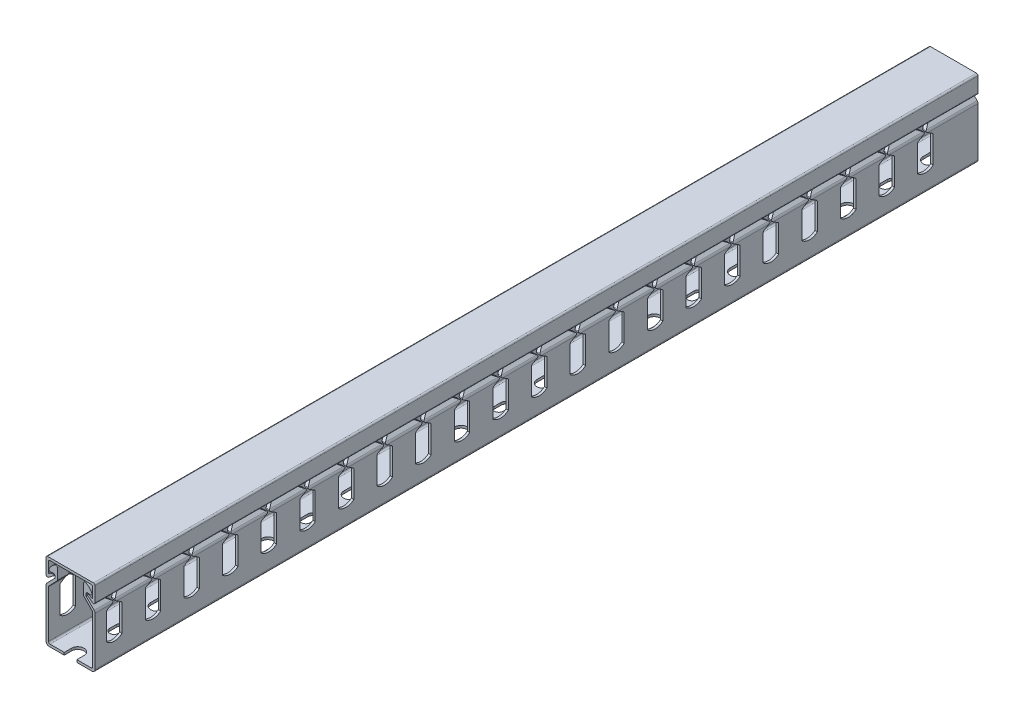
from build123d import *

# Parameters (mm, degrees)
BOSS_EXTRUDE1_DEPTH        = 228.6
BOSS_EXTRUDE1_DEPTH_BACK   = 228.6
BOSS_EXTRUDE1_2_DEPTH      = 228.6
BOSS_EXTRUDE1_2_DEPTH_BACK = 228.6
FILLET1_R                  = 0.254
FILLET2_R                  = 0.79375
FILLET3_R                  = 1.5875
FILLET4_R                  = 0.79375
CUT_EXTRUDE2_DEPTH         = 13.7
LPATTERN2_COUNT            = 22
LPATTERN2_PITCH            = 20
CUT_EXTRUDE3_DEPTH         = 1.27
CUT_EXTRUDE4_DEPTH         = 1.27
LPATTERN3_COUNT            = 10
LPATTERN3_PITCH            = 50


with BuildPart() as part:
    # Sketch5 → Boss-Extrude1 (new body, two sides)
    with BuildSketch(Plane.XY) as boss_extrude1_sk:
        with BuildLine():
            Line((-6.80847, 17.42825), (-6.80847, 11.601073654))
            Line((-6.80847, 11.601073654), (-11.43, 6.8817226))
            Line((-11.43, 6.8817226), (-11.43, -18.73))
            Line((-11.43, -18.73), (11.43, -18.73))
            Line((11.43, -18.73), (11.43, 6.8817226))
            Line((11.43, 6.8817226), (6.80847, 11.601073654))
            Line((6.80847, 11.601073654), (6.80847, 17.42825))
            ThreePointArc((6.80847, 17.42825), (7.19761808, 18.11113824), (7.983490721, 18.124433668))
            ThreePointArc((7.983490721, 18.124433668), (9.75568161, 16.763244384), (11.032082377, 14.929042133))
            ThreePointArc((11.032082377, 14.929042133), (10.954803473, 14.106067876), (10.187743463, 13.798045804))
            Line((10.187743463, 13.798045804), (8.07847, 14.151017128))
            Line((8.07847, 14.151017128), (8.07847, 12.119351053))
            Line((8.07847, 12.119351053), (12.7, 7.4))
            Line((12.7, 7.4), (12.7, -20))
            Line((12.7, -20), (-12.7, -20))
            Line((-12.7, -20), (-12.7, 7.4))
            Line((-12.7, 7.4), (-8.07847, 12.119351053))
            Line((-8.07847, 12.119351053), (-8.07847, 14.151017128))
            Line((-8.07847, 14.151017128), (-10.187743463, 13.798045804))
            ThreePointArc((-10.187743463, 13.798045804), (-10.954803473, 14.106067876), (-11.032082377, 14.929042133))
            ThreePointArc((-11.032082377, 14.929042133), (-9.75568161, 16.763244384), (-7.983490721, 18.124433668))
            ThreePointArc((-7.983490721, 18.124433668), (-7.19761808, 18.11113824), (-6.80847, 17.42825))
        make_face()
    extrude(amount=BOSS_EXTRUDE1_DEPTH)
    extrude(boss_extrude1_sk.sketch, amount=-BOSS_EXTRUDE1_DEPTH_BACK)

    # Fillet3
    fillet3_edges = [part.edges().sort_by_distance(p)[0] for p in [
        (12.7, 7.4, 0),
        (12.7, -20, 0),
        (-12.7, -20, 0),
        (-12.7, 7.4, 0),
    ]]
    fillet(fillet3_edges, radius=FILLET3_R)

    # Fillet4
    fillet4_edges = [part.edges().sort_by_distance(p)[0] for p in [
        (-6.80847, 11.601073654, 0),
        (-11.43, 6.8817226, 0),
        (-11.43, -18.73, 0),
        (11.43, -18.73, 0),
        (11.43, 6.8817226, 0),
        (6.80847, 11.601073654, 0),
        (8.07847, 14.151017128, 0),
        (-8.07847, 14.151017128, 0),
    ]]
    fillet(fillet4_edges, radius=FILLET4_R)

    # Sketch6 → Cut-Extrude2 (cut, symmetric)
    with BuildSketch(Plane(origin=(0, 0, 0), x_dir=(0, 0, -1), z_dir=(1, 0, 0))):
        with BuildLine():
            Line((-222.6, 20), (-222.6, 10.281402782))
            ThreePointArc((-222.6, 10.281402782), (-222.501317282, 9.898100634), (-222.229806522, 9.610106323))
            Line((-222.229806522, 9.610106323), (-219.258970247, 7.735648229))
            ThreePointArc((-219.258970247, 7.735648229), (-219.073873508, 7.4), (-219.258970247, 7.064351771))
            Line((-219.258970247, 7.064351771), (-222.229806522, 5.189893677))
            ThreePointArc((-222.229806522, 5.189893677), (-222.501317282, 4.901899366), (-222.6, 4.518597218))
            Line((-222.6, 4.518597218), (-222.6, -9.1796))
            ThreePointArc((-222.6, -9.1796), (-218.6, -10.707464045), (-214.6, -9.1796))
            Line((-214.6, -9.1796), (-214.6, 4.518597218))
            ThreePointArc((-214.6, 4.518597218), (-214.698682718, 4.901899366), (-214.970193478, 5.189893677))
            Line((-214.970193478, 5.189893677), (-217.941029753, 7.064351771))
            ThreePointArc((-217.941029753, 7.064351771), (-218.126126492, 7.4), (-217.941029753, 7.735648229))
            Line((-217.941029753, 7.735648229), (-214.970193478, 9.610106323))
            ThreePointArc((-214.970193478, 9.610106323), (-214.698682718, 9.898100634), (-214.6, 10.281402782))
            Line((-214.6, 10.281402782), (-214.6, 20))
            Line((-214.6, 20), (-222.6, 20))
        make_face()
    cut_extrude2 = extrude(amount=CUT_EXTRUDE2_DEPTH, both=True, mode=Mode.SUBTRACT)

    # LPattern2: Cut-Extrude2 ×22
    with Locations(*[(0, 0, -i * LPATTERN2_PITCH) for i in range(1, LPATTERN2_COUNT)]):
        add(cut_extrude2, mode=Mode.SUBTRACT)

    # Sketch7 → Cut-Extrude3 (cut)
    with BuildSketch(Plane.XZ.offset(20)):
        with BuildLine():
            Line((-3.25, 232.35), (-3.25, 224.85))
            ThreePointArc((-3.25, 224.85), (0, 221.6), (3.25, 224.85))
            Line((3.25, 224.85), (3.25, 232.35))
            ThreePointArc((3.25, 232.35), (0, 235.6), (-3.25, 232.35))
        make_face()
        with BuildLine():
            Line((-2.25, 206.1), (-2.25, 202.6))
            ThreePointArc((-2.25, 202.6), (0, 200.35), (2.25, 202.6))
            Line((2.25, 202.6), (2.25, 206.1))
            ThreePointArc((2.25, 206.1), (0, 208.35), (-2.25, 206.1))
        make_face()
    extrude(amount=-CUT_EXTRUDE3_DEPTH, mode=Mode.SUBTRACT)

    # Sketch8 → Cut-Extrude4 (cut)
    with BuildSketch(Plane.XZ.offset(20)):
        with BuildLine():
            Line((-2.25, 153.35), (-2.25, 156.85))
            ThreePointArc((-2.25, 156.85), (0, 159.1), (2.25, 156.85))
            Line((2.25, 156.85), (2.25, 153.35))
            ThreePointArc((2.25, 153.35), (0, 151.1), (-2.25, 153.35))
        make_face()
        with BuildLine():
            Line((3.25, 183.85), (3.25, 176.35))
            ThreePointArc((3.25, 176.35), (0, 173.1), (-3.25, 176.35))
            Line((-3.25, 176.35), (-3.25, 183.85))
            ThreePointArc((-3.25, 183.85), (0, 187.1), (3.25, 183.85))
        make_face()
    cut_extrude4 = extrude(amount=-CUT_EXTRUDE4_DEPTH, mode=Mode.SUBTRACT)

    # LPattern3: Cut-Extrude4 ×10
    with Locations(*[(0, 0, -i * LPATTERN3_PITCH) for i in range(1, LPATTERN3_COUNT)]):
        add(cut_extrude4, mode=Mode.SUBTRACT)


with BuildPart() as body_2:
    # Sketch5 → Boss-Extrude1 2 (new body, two sides)
    with BuildSketch(Plane.XY) as boss_extrude1_2_sk:
        with BuildLine():
            Line((-12.7, 20), (-12.7, 11.49227))
            ThreePointArc((-12.7, 11.49227), (-12.263515638, 10.783467964), (-11.434109413, 10.854208617))
            Line((-11.434109413, 10.854208617), (-8.751188909, 12.839465357))
            ThreePointArc((-8.751188909, 12.839465357), (-8.610572709, 13.282073626), (-8.98688149, 13.554225599))
            ThreePointArc((-8.98688149, 13.554225599), (-9.873382015, 13.411834461), (-10.670699038, 12.998985842))
            Line((-10.670699038, 12.998985842), (-11.43, 12.437132686))
            Line((-11.43, 12.437132686), (-11.43, 18.73))
            Line((-11.43, 18.73), (11.43, 18.73))
            Line((11.43, 18.73), (11.43, 12.437132686))
            Line((11.43, 12.437132686), (10.670699038, 12.998985842))
            ThreePointArc((10.670699038, 12.998985842), (9.873382015, 13.411834461), (8.98688149, 13.554225599))
            ThreePointArc((8.98688149, 13.554225599), (8.610572709, 13.282073626), (8.751188909, 12.839465357))
            Line((8.751188909, 12.839465357), (11.434109413, 10.854208617))
            ThreePointArc((11.434109413, 10.854208617), (12.263515638, 10.783467964), (12.7, 11.49227))
            Line((12.7, 11.49227), (12.7, 20))
            Line((12.7, 20), (-12.7, 20))
        make_face()
    extrude(amount=BOSS_EXTRUDE1_2_DEPTH)
    extrude(boss_extrude1_2_sk.sketch, amount=-BOSS_EXTRUDE1_2_DEPTH_BACK)

    # Fillet1
    fillet1_edges = [body_2.edges().sort_by_distance(p)[0] for p in [
        (11.43, 12.437132686, 0),
        (-11.43, 12.437132686, 0),
    ]]
    fillet(fillet1_edges, radius=FILLET1_R)

    # Fillet2
    fillet2_edges = [body_2.edges().sort_by_distance(p)[0] for p in [
        (12.7, 20, 0),
        (11.43, 18.73, 0),
        (-11.43, 18.73, 0),
        (-12.7, 20, 0),
    ]]
    fillet(fillet2_edges, radius=FILLET2_R)


solid = Compound([part.part, body_2.part])
